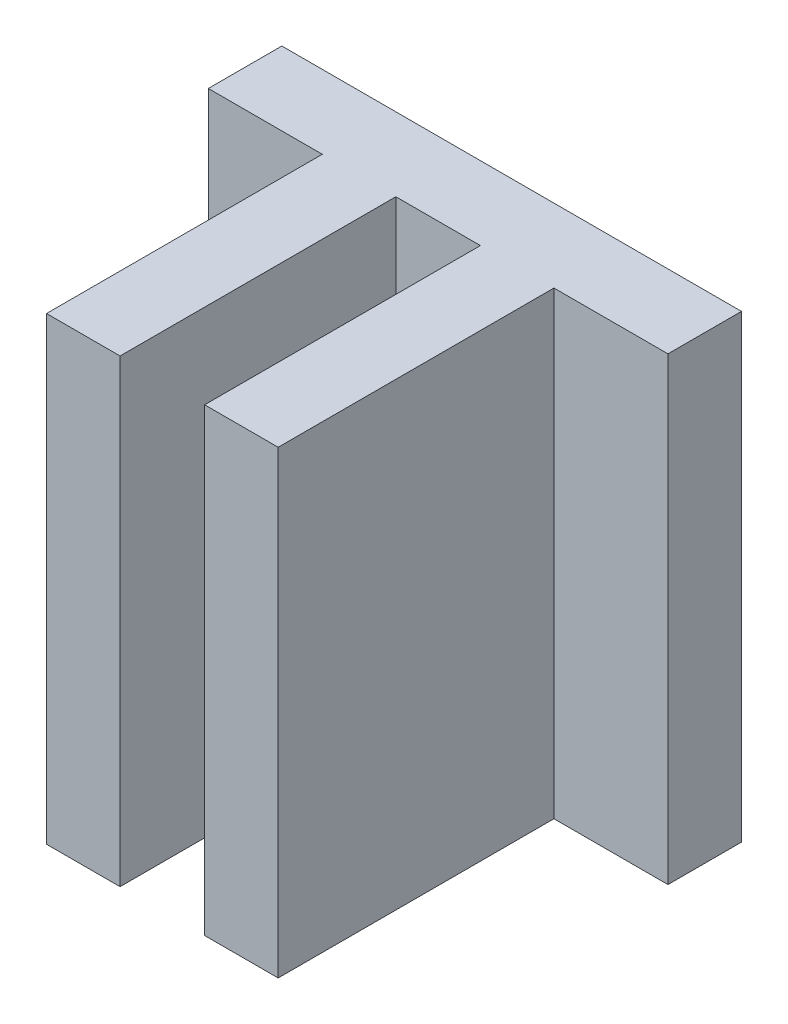
from build123d import *

# Parameters (mm, degrees)
SKETCH1_W           = 3.937
SKETCH1_H           = 2.54
BOSS_EXTRUDE1_DEPTH = 15.875


with BuildPart() as part:
    # Sketch1 → Boss-Extrude1 (new body)
    with BuildSketch(Plane(origin=(0, 0, 0), x_dir=(1, 0, 0), z_dir=(0, 1, 0))):
        Polygon((4.0005, 2.54), (-4.0005, 2.54), (-4.0005, 0), (-4.0005, -9.525), (-1.4605, -9.525), (-1.4605, 0), (1.4605, 0), (1.4605, -9.525), (4.0005, -9.525), (4.0005, 0), align=None)
        with Locations((-5.969, 1.27)):
            Rectangle(SKETCH1_W, SKETCH1_H)
        with Locations((5.969, 1.27)):
            Rectangle(SKETCH1_W, SKETCH1_H)
    extrude(amount=BOSS_EXTRUDE1_DEPTH)


solid = part.part
